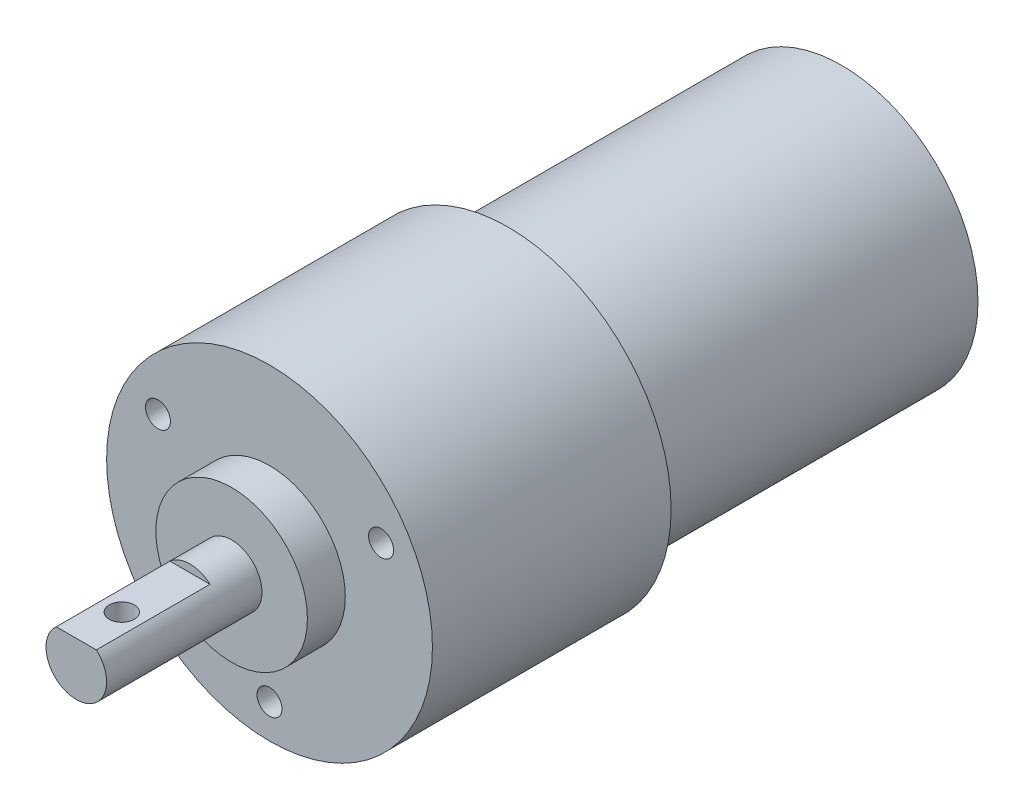
from build123d import *

# Parameters (mm, degrees)
SKETCH_1_R          = 21.5
SKETCH_1_R_2        = 18
EXTRUDE_1_DEPTH     = 31.5
SKETCH_1_3_R        = 18
EXTRUDE_2_DEPTH     = 44
SKETCH_2_R          = 10
SKETCH_2_R_2        = 4
EXTRUDE_3_DEPTH     = 5
SKETCH_2_2_R        = 4
EXTRUDE_4_DEPTH     = 25.5
CUT_EXTRUDE_START   = 3
SKETCH_3_W          = 15.90617044
SKETCH_3_H          = 15
CUT_EXTRUDE_1_DEPTH = 62.602631525
M4X0_7_1_D          = 3.3
M4X0_7_1_DEPTH      = 11.5
M4X0_7_1_TIP        = 0.991420021
M4X0_7_2_D          = 3.3


with BuildPart() as part:
    # ｽｹｯﾁ1 → ﾎﾞｽ - 押し出し1 (new body)
    with BuildSketch(Plane.XY):
        Circle(SKETCH_1_R)
        Circle(SKETCH_1_R_2, mode=Mode.SUBTRACT)
        Circle(SKETCH_1_R_2)
    extrude(amount=EXTRUDE_1_DEPTH)

    # ｽｹｯﾁ1<3> → ﾎﾞｽ - 押し出し2 (add)
    with BuildSketch(Plane.XY):
        Circle(SKETCH_1_3_R)
    extrude(amount=-EXTRUDE_2_DEPTH)

    # ｽｹｯﾁ2 → ﾎﾞｽ - 押し出し3 (add)
    with BuildSketch(Plane.XY.offset(31.5)):
        Circle(SKETCH_2_R)
        Circle(SKETCH_2_R_2, mode=Mode.SUBTRACT)
    extrude(amount=EXTRUDE_3_DEPTH)

    # ｽｹｯﾁ2<2> → ﾎﾞｽ - 押し出し4 (add)
    with BuildSketch(Plane.XY.offset(31.5)):
        Circle(SKETCH_2_2_R)
    extrude(amount=EXTRUDE_4_DEPTH)

    # ｽｹｯﾁ3 → ｶｯﾄ - 押し出し1 (cut, through all)
    with BuildSketch(Plane(origin=(0, 0, 0), x_dir=(1, 0, 0), z_dir=(0, 1, 0)).offset(CUT_EXTRUDE_START)):
        with Locations((0, -49.5)):
            Rectangle(SKETCH_3_W, SKETCH_3_H)
    extrude(amount=CUT_EXTRUDE_1_DEPTH, mode=Mode.SUBTRACT)

    # M4x0.7 ねじ穴1
    with Locations(Plane.XY.offset(31.5)):
        with Locations((0, -17), (-14.722431864, 8.5), (14.722431864, 8.5)):
            Hole(M4X0_7_1_D / 2, depth=M4X0_7_1_DEPTH)
            with Locations((0, 0, -(M4X0_7_1_DEPTH + M4X0_7_1_TIP / 2))):  # 118° drill point
                Cone(0, M4X0_7_1_D / 2, M4X0_7_1_TIP, mode=Mode.SUBTRACT)

    # M4x0.7 ねじ穴2 (through all)
    with Locations(Plane(origin=(0, 3, 0), x_dir=(1, 0, 0), z_dir=(0, 1, 0))):
        with Locations((0, -51)):
            Hole(M4X0_7_2_D / 2)


solid = part.part
